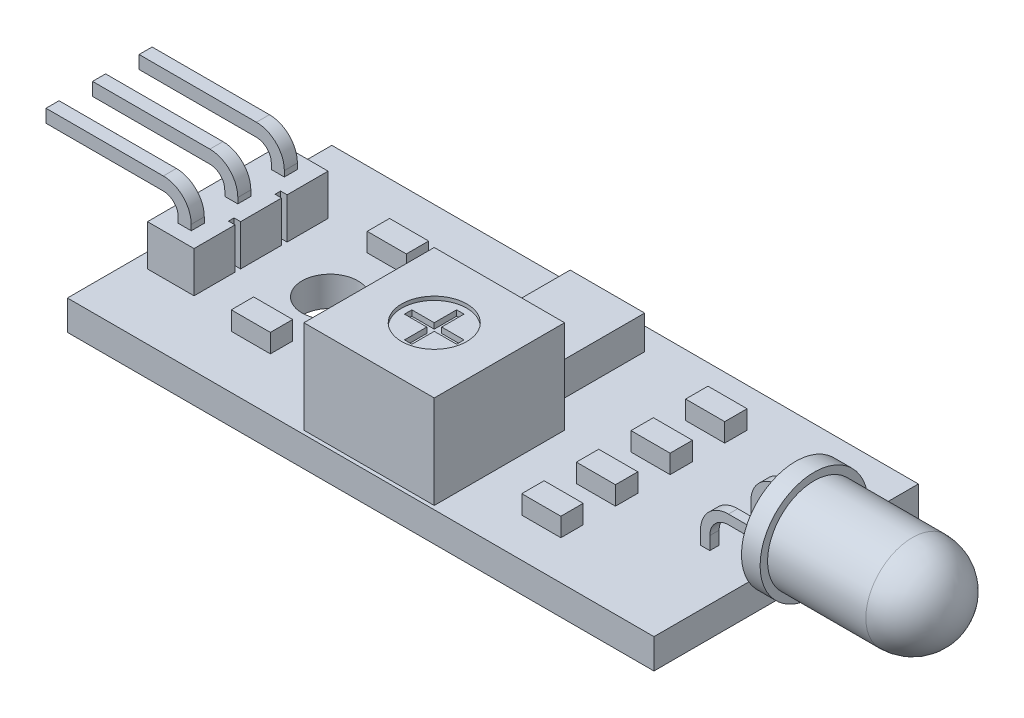
from build123d import *

# Parameters (mm, degrees)
SKETCH_1_W             = 31.5
SKETCH_1_H             = 14.2
SKETCH_1_R             = 1.5
EXTRUDE_1_DEPTH        = 1.6
SKETCH_2_W             = 7
SKETCH_2_H             = 7
EXTRUDE_2_DEPTH        = 5
SKETCH_3_R             = 1.75
CUT_EXTRUDE_1_DEPTH    = 0.2
CUT_EXTRUDE_2_DEPTH    = 0.3
SKETCH_6_W             = 4
SKETCH_6_H             = 4.5
EXTRUDE_3_DEPTH        = 1.8
SKETCH_7_W             = 2.1
SKETCH_7_H             = 1.2
SKETCH_7_W_2           = 1.2
SKETCH_7_H_2           = 2.1
EXTRUDE_4_DEPTH        = 1
EXTRUDE_START          = 1.6
EXTRUDE_5_DEPTH        = 0.5
PATTERN_LINEAR_1_COUNT = 2
PATTERN_LINEAR_1_PITCH = 2.7
EXTRUDE_6_DEPTH        = 0.35
PATTERN_LINEAR_2_COUNT = 2
PATTERN_LINEAR_2_PITCH = 2.5
PATTERN_LINEAR_3_COUNT = 2
PATTERN_LINEAR_3_PITCH = 2.5
SKETCH_12_W            = 2.5
SKETCH_12_H            = 2.2
SKETCH_12_W_2          = 1.8
SKETCH_12_H_2          = 0.3
EXTRUDE_7_DEPTH        = 2.2
SKETCH_13_R            = 0.4
EXTRUDE_8_DEPTH        = 0.5
SCALE1_SCALE           = 0.04762


with BuildPart() as part:
    # Эскиз1 → Бобышка-Вытянуть1 (new body)
    with BuildSketch(Plane(origin=(0, 0, 0), x_dir=(1, 0, 0), z_dir=(0, 1, 0))):
        Rectangle(SKETCH_1_W, SKETCH_1_H)
        with Locations((-8.75, 0)):
            Circle(SKETCH_1_R, mode=Mode.SUBTRACT)
    extrude(amount=EXTRUDE_1_DEPTH)

    # Эскиз2 → Бобышка-Вытянуть2 (add)
    with BuildSketch(Plane(origin=(0, 1.6, 0), x_dir=(1, 0, 0), z_dir=(0, 1, 0))):
        with Locations((0.25, -3.4)):
            Rectangle(SKETCH_2_W, SKETCH_2_H)
    extrude(amount=EXTRUDE_2_DEPTH)

    # Эскиз3 → Вырез-Вытянуть1 (cut)
    with BuildSketch(Plane(origin=(0, 6.6, 0), x_dir=(1, 0, 0), z_dir=(0, 1, 0))):
        with Locations((0.25, -3.4)):
            Circle(SKETCH_3_R)
    extrude(amount=-CUT_EXTRUDE_1_DEPTH, mode=Mode.SUBTRACT)

    # Эскиз4 → Вырез-Вытянуть2 (cut)
    with BuildSketch(Plane(origin=(0, 6.4, 0), x_dir=(1, 0, 0), z_dir=(0, 1, 0))):
        Polygon((0.05, -2), (0.45, -2), (0.45, -3.2), (1.65, -3.2), (1.65, -3.6), (0.45, -3.6), (0.45, -4.8), (0.05, -4.8), (0.05, -3.6), (-1.15, -3.6), (-1.15, -3.2), (0.05, -3.2), align=None)
    extrude(amount=-CUT_EXTRUDE_2_DEPTH, mode=Mode.SUBTRACT)

    # Эскиз6 → Бобышка-Вытянуть3 (add)
    with BuildSketch(Plane(origin=(0, 1.6, 0), x_dir=(1, 0, 0), z_dir=(0, 1, 0))):
        with Locations((0.25, 3.65)):
            Rectangle(SKETCH_6_W, SKETCH_6_H)
    extrude(amount=EXTRUDE_3_DEPTH)

    # Эскиз7 → Бобышка-Вытянуть4 (add)
    with BuildSketch(Plane(origin=(0, 1.6, 0), x_dir=(1, 0, 0), z_dir=(0, 1, 0))):
        with Locations((7.6, 1.466666667)):
            Rectangle(SKETCH_7_W, SKETCH_7_H)
        with Locations((7.6, 4.4)):
            Rectangle(SKETCH_7_W, SKETCH_7_H)
        with Locations((-8.75, 3.65)):
            Rectangle(SKETCH_7_W, SKETCH_7_H)
        with Locations((-5.15, 2.95)):
            Rectangle(SKETCH_7_W_2, SKETCH_7_H_2)
        with Locations((-5.15, -2.95)):
            Rectangle(SKETCH_7_W_2, SKETCH_7_H_2)
        with Locations((-8.75, -3.65)):
            Rectangle(SKETCH_7_W, SKETCH_7_H)
        with Locations((7.6, -4.4)):
            Rectangle(SKETCH_7_W, SKETCH_7_H)
        with Locations((7.6, -1.466666667)):
            Rectangle(SKETCH_7_W, SKETCH_7_H)
    extrude(amount=EXTRUDE_4_DEPTH)

    # Эскиз9 → Бобышка-Вытянуть5 (add)
    with BuildSketch(Plane.XY.offset(EXTRUDE_START)):
        with BuildLine():
            Line((12.75, 2.3), (12.75, -0.5))
            Line((12.75, -0.5), (13.25, -0.5))
            Line((13.25, -0.5), (13.25, 2.3))
            ThreePointArc((13.25, 2.3), (13.542893219, 3.007106781), (14.25, 3.3))
            Line((14.25, 3.3), (16.25, 3.3))
            Line((16.25, 3.3), (16.25, 3.8))
            Line((16.25, 3.8), (14.25, 3.8))
            ThreePointArc((14.25, 3.8), (13.189339828, 3.360660172), (12.75, 2.3))
        make_face()
    extrude_5 = extrude(amount=-EXTRUDE_5_DEPTH)

    # Линейный массив1: Бобышка-Вытянуть5 ×2
    with Locations(*[(0, 0, -i * PATTERN_LINEAR_1_PITCH) for i in range(1, PATTERN_LINEAR_1_COUNT)]):
        add(extrude_5)

    # Эскиз10 → Повернуть1 (revolve)
    with BuildSketch(Plane.XY):
        with BuildLine():
            Line((16.25, 3.55), (16.25, 6.45))
            Line((16.25, 6.45), (17.25, 6.45))
            Line((17.25, 6.45), (17.25, 6.05))
            Line((17.25, 6.05), (22.53, 6.05))
            ThreePointArc((22.53, 6.05), (24.297766953, 5.317766953), (25.03, 3.55))
            Line((25.03, 3.55), (16.25, 3.55))
        make_face()
    revolve(axis=Axis((16.25, 3.55, 0), (1, 0, 0)))

    # Эскиз11 → Бобышка-Вытянуть6 (add, symmetric)
    with BuildSketch(Plane.XY):
        with BuildLine():
            Line((-13.35, -0.5), (-14.05, -0.5))
            Line((-14.05, -0.5), (-14.05, 4.1))
            ThreePointArc((-14.05, 4.1), (-14.284314575, 4.665685425), (-14.85, 4.9))
            Line((-14.85, 4.9), (-21.15, 4.9))
            Line((-21.15, 4.9), (-21.15, 5.6))
            Line((-21.15, 5.6), (-14.85, 5.6))
            ThreePointArc((-14.85, 5.6), (-13.789339828, 5.160660172), (-13.35, 4.1))
            Line((-13.35, 4.1), (-13.35, -0.5))
        make_face()
    extrude_6 = extrude(amount=EXTRUDE_6_DEPTH, both=True)

    # Линейный массив2: Бобышка-Вытянуть6 ×2
    with Locations(*[(0, 0, i * PATTERN_LINEAR_2_PITCH) for i in range(1, PATTERN_LINEAR_2_COUNT)]):
        add(extrude_6)

    # Линейный массив3: Бобышка-Вытянуть6 ×2
    with Locations(*[(0, 0, -i * PATTERN_LINEAR_3_PITCH) for i in range(1, PATTERN_LINEAR_3_COUNT)]):
        add(extrude_6)

    # Эскиз12 → Бобышка-Вытянуть7 (add)
    with BuildSketch(Plane(origin=(0, 1.6, 0), x_dir=(1, 0, 0), z_dir=(0, 1, 0))):
        with Locations((-13.7, 2.5)):
            Rectangle(SKETCH_12_W, SKETCH_12_H)
        with Locations((-13.7, 1.25)):
            Rectangle(SKETCH_12_W_2, SKETCH_12_H_2)
        with Locations((-13.7, 0)):
            Rectangle(SKETCH_12_W, SKETCH_12_H)
        with Locations((-13.7, -1.25)):
            Rectangle(SKETCH_12_W_2, SKETCH_12_H_2)
        with Locations((-13.7, -2.5)):
            Rectangle(SKETCH_12_W, SKETCH_12_H)
    extrude(amount=EXTRUDE_7_DEPTH)

    # Эскиз13 → Бобышка-Вытянуть8 (add)
    with BuildSketch(Plane.XZ):
        with Locations((-2.25, 3.6)):
            Circle(SKETCH_13_R)
        with Locations((0.25, 1.1)):
            Circle(SKETCH_13_R)
        with Locations((2.75, 3.6)):
            Circle(SKETCH_13_R)
    extrude(amount=EXTRUDE_8_DEPTH)


with BuildPart() as part_1:
    # Scale1: scaled about (0, 0, 0)
    add(part.part.scale(SCALE1_SCALE))


solid = part_1.part
